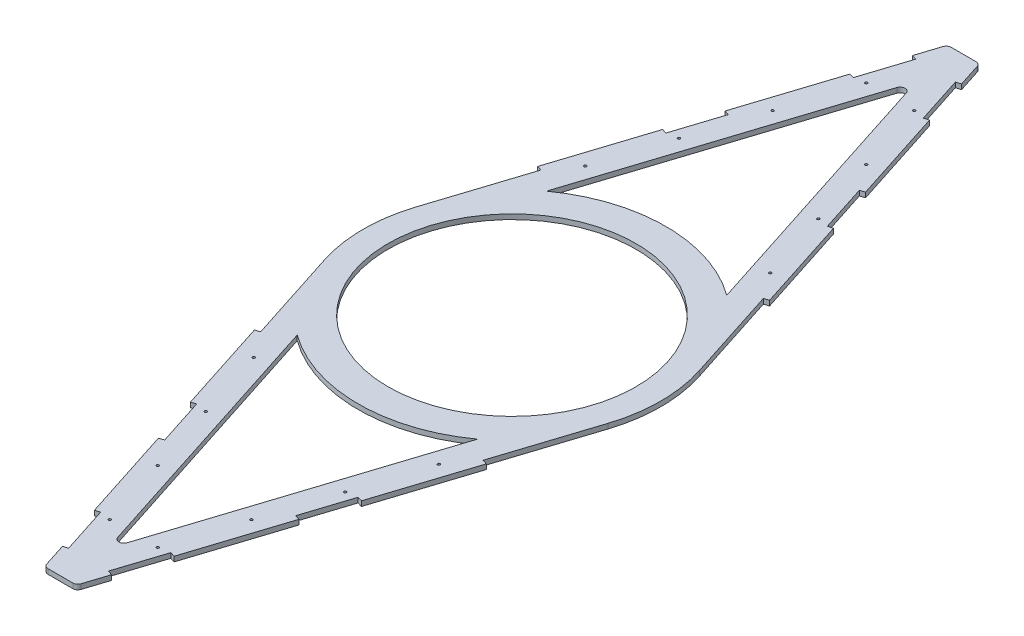
from build123d import *

# Parameters (mm, degrees)
SKETCH2_R           = 2.5
SKETCH2_R_2         = 250
BOSS_EXTRUDE1_DEPTH = 10
CUT_EXTRUDE1_DEPTH  = 11


with BuildPart() as part:
    # Sketch2 → Boss-Extrude1 (new body)
    with BuildSketch(Plane(origin=(0, 0, 0), x_dir=(1, 0, 0), z_dir=(0, 1, 0))):
        with BuildLine():
            Line((-34.517430478, 903.068960265), (-295.040344804, 95.1377682))
            ThreePointArc((-295.040344804, 95.1377682), (-310, 0), (-295.040344804, -95.1377682))
            Line((-295.040344804, -95.1377682), (-34.517430478, -903.068960265))
            ThreePointArc((-34.517430478, -903.068960265), (-30.886866626, -908.083613135), (-25, -910))
            Line((-25, -910), (25, -910))
            ThreePointArc((25, -910), (30.886866626, -908.083613135), (34.517430478, -903.068960265))
            Line((34.517430478, -903.068960265), (295.040344804, -95.1377682))
            ThreePointArc((295.040344804, -95.1377682), (310, 0), (295.040344804, 95.1377682))
            Line((295.040344804, 95.1377682), (34.517430478, 903.068960265))
            ThreePointArc((34.517430478, 903.068960265), (30.886866626, 908.083613135), (25, 910))
            Line((25, 910), (-25, 910))
            ThreePointArc((-25, 910), (-30.886866626, 908.083613135), (-34.517430478, 903.068960265))
        make_face()
        with Locations((-48.373467006, -762.345774842)):
            Circle(SKETCH2_R, mode=Mode.SUBTRACT)
        with Locations((-94.407870974, -619.584317679)):
            Circle(SKETCH2_R, mode=Mode.SUBTRACT)
        with Locations((-140.442274942, -476.822860516)):
            Circle(SKETCH2_R, mode=Mode.SUBTRACT)
        with BuildLine():
            ThreePointArc((-181.680791071, -251.181388952), (0, -310), (181.680791071, -251.181388952))
            Line((181.680791071, -251.181388952), (9.517430478, -785.092770658))
            ThreePointArc((9.517430478, -785.092770658), (0, -792.023810393), (-9.517430478, -785.092770658))
            Line((-9.517430478, -785.092770658), (-181.680791071, -251.181388952))
        make_face(mode=Mode.SUBTRACT)
        with Locations((-186.476678909, -334.061403353)):
            Circle(SKETCH2_R, mode=Mode.SUBTRACT)
        with Locations((48.373467006, -762.345774842)):
            Circle(SKETCH2_R, mode=Mode.SUBTRACT)
        with Locations((94.407870974, -619.584317679)):
            Circle(SKETCH2_R, mode=Mode.SUBTRACT)
        with Locations((140.442274942, -476.822860516)):
            Circle(SKETCH2_R, mode=Mode.SUBTRACT)
        with Locations((186.476678909, -334.061403353)):
            Circle(SKETCH2_R, mode=Mode.SUBTRACT)
        with Locations((-186.476678909, 334.061403353)):
            Circle(SKETCH2_R, mode=Mode.SUBTRACT)
        with Locations((-140.442274942, 476.822860516)):
            Circle(SKETCH2_R, mode=Mode.SUBTRACT)
        with Locations((-94.407870974, 619.584317679)):
            Circle(SKETCH2_R, mode=Mode.SUBTRACT)
        with BuildLine():
            ThreePointArc((181.680791071, 251.181388952), (0, 310), (-181.680791071, 251.181388952))
            Line((-181.680791071, 251.181388952), (-9.517430478, 785.092770658))
            ThreePointArc((-9.517430478, 785.092770658), (0, 792.023810393), (9.517430478, 785.092770658))
            Line((9.517430478, 785.092770658), (181.680791071, 251.181388952))
        make_face(mode=Mode.SUBTRACT)
        with Locations((-48.373467006, 762.345774842)):
            Circle(SKETCH2_R, mode=Mode.SUBTRACT)
        Circle(SKETCH2_R_2, mode=Mode.SUBTRACT)
        with Locations((186.476678909, 334.061403353)):
            Circle(SKETCH2_R, mode=Mode.SUBTRACT)
        with Locations((140.442274942, 476.822860516)):
            Circle(SKETCH2_R, mode=Mode.SUBTRACT)
        with Locations((94.407870974, 619.584317679)):
            Circle(SKETCH2_R, mode=Mode.SUBTRACT)
        with Locations((48.373467006, 762.345774842)):
            Circle(SKETCH2_R, mode=Mode.SUBTRACT)
    extrude(amount=BOSS_EXTRUDE1_DEPTH)

    # Sketch3 → Cut-Extrude1 (cut, through all)
    with BuildSketch(Plane(origin=(0, 10, 0), x_dir=(1, 0, 0), z_dir=(0, 1, 0))):
        Polygon((-49.523523643, -856.532206403), (-40.006093165, -853.463246139), (-70.69569581, -758.288941363), (-80.213126288, -761.357901628), align=None)
        Polygon((-132.074901101, -567.940331812), (-141.592331578, -571.009292077), (-172.281934223, -475.834987302), (-162.764503746, -472.766027037), align=None)
        with BuildLine():
            Line((-233.661139514, -285.486377751), (-224.143709036, -282.417417486))
            Line((-224.143709036, -282.417417486), (-285.522914326, -92.068807935))
            ThreePointArc((-285.522914326, -92.068807935), (-300, 0), (-285.522914326, 92.068807935))
            Line((-285.522914326, 92.068807935), (-224.143709036, 282.417417486))
            Line((-224.143709036, 282.417417486), (-233.661139514, 285.486377751))
            Line((-233.661139514, 285.486377751), (-295.040344804, 95.1377682))
            ThreePointArc((-295.040344804, 95.1377682), (-310, 0), (-295.040344804, -95.1377682))
            Line((-295.040344804, -95.1377682), (-233.661139514, -285.486377751))
        make_face()
        Polygon((-49.523523643, 856.532206403), (-40.006093165, 853.463246139), (-70.69569581, 758.288941363), (-80.213126288, 761.357901628), align=None)
        Polygon((-162.764503746, 472.766027037), (-132.074901101, 567.940331812), (-141.592331578, 571.009292077), (-172.281934223, 475.834987302), align=None)
        Polygon((49.523523643, 856.532206403), (40.006093165, 853.463246139), (70.69569581, 758.288941363), (80.213126288, 761.357901628), align=None)
        Polygon((49.523523643, -856.532206403), (40.006093165, -853.463246139), (70.69569581, -758.288941363), (80.213126288, -761.357901628), align=None)
        Polygon((132.074901101, 567.940331812), (141.592331578, 571.009292077), (172.281934223, 475.834987302), (162.764503746, 472.766027037), align=None)
        with BuildLine():
            Line((233.661139514, 285.486377751), (224.143709036, 282.417417486))
            Line((224.143709036, 282.417417486), (285.522914326, 92.068807935))
            ThreePointArc((285.522914326, 92.068807935), (300, 0), (285.522914326, -92.068807935))
            Line((285.522914326, -92.068807935), (224.143709036, -282.417417486))
            Line((224.143709036, -282.417417486), (233.661139514, -285.486377751))
            Line((233.661139514, -285.486377751), (295.040344804, -95.1377682))
            ThreePointArc((295.040344804, -95.1377682), (310, 0), (295.040344804, 95.1377682))
            Line((295.040344804, 95.1377682), (233.661139514, 285.486377751))
        make_face()
        Polygon((162.764503746, -472.766027037), (132.074901101, -567.940331812), (141.592331578, -571.009292077), (172.281934223, -475.834987302), align=None)
    extrude(amount=-CUT_EXTRUDE1_DEPTH, mode=Mode.SUBTRACT)


solid = part.part
